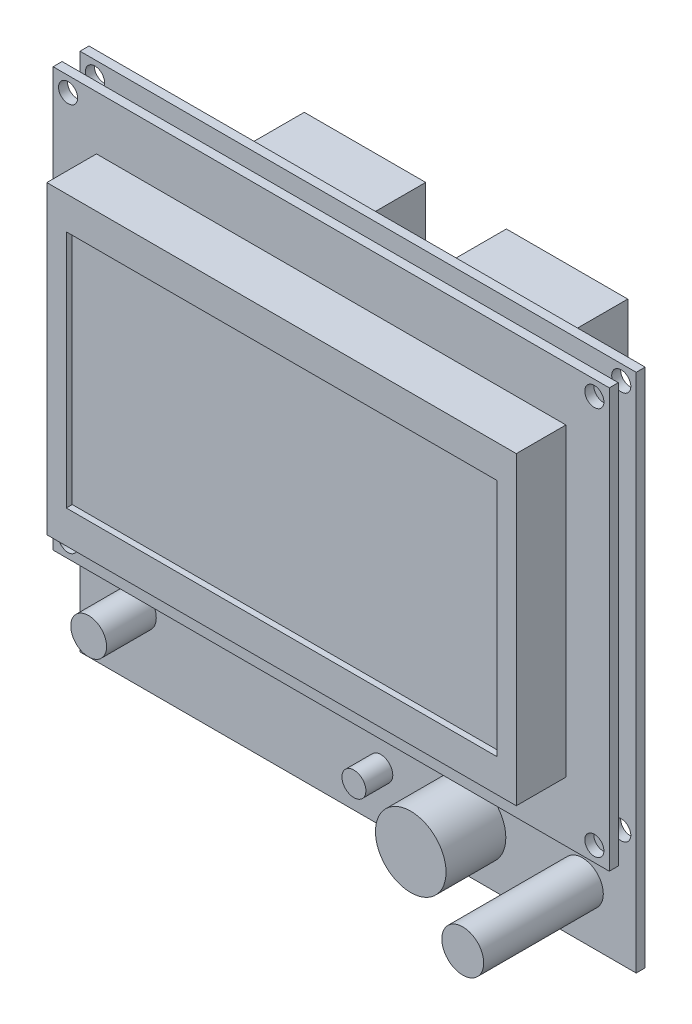
from build123d import *

# Parameters (mm, degrees)
ESBO_O1_W                  = 93
ESBO_O1_H                  = 87
RESSALTO_EXTRUS_O1_DEPTH   = 1.5
RESSALTO_EXTRUS_O2_START   = 3
ESBO_O3_W                  = 93
ESBO_O3_H                  = 70
RESSALTO_EXTRUS_O2_DEPTH   = 1.5
ESBO_O4_W                  = 78.5
ESBO_O4_H                  = 51
RESSALTO_EXTRUS_O3_DEPTH   = 8.3
ESBO_O5_W                  = 72
ESBO_O5_H                  = 40
CORTE_EXTRUS_O1_DEPTH      = 1
ESBO_O6_R                  = 3.5
RESSALTO_EXTRUS_O4_DEPTH   = 20
ESBO_O7_R                  = 2
RESSALTO_EXTRUS_O5_DEPTH   = 4.5
ESBO_O8_R                  = 5.9
RESSALTO_EXTRUS_O6_DEPTH   = 10
ESBO_O9_R                  = 3
RESSALTO_EXTRUS_O7_DEPTH   = 8.3
ESBO_O10_R                 = 1.6
CORTE_EXTRUS_O2_DEPTH      = 16.5
CORTE_EXTRUS_O2_DEPTH_BACK = 7
ESBO_O11_W                 = 20.3
ESBO_O11_H                 = 8.6
RESSALTO_EXTRUS_O8_DEPTH   = 15
ESBO_O12_W                 = 25.5
ESBO_O12_H                 = 26.5
RESSALTO_EXTRUS_O9_DEPTH   = 3


with BuildPart() as part:
    # Esboço1 → Ressalto-extrusão1 (new body)
    with BuildSketch(Plane.XY):
        Rectangle(ESBO_O1_W, ESBO_O1_H)
    extrude(amount=RESSALTO_EXTRUS_O1_DEPTH)

    # Esboço6 → Ressalto-extrusão4 (add)
    with BuildSketch(Plane.XY.offset(1.5)):
        with Locations((37.5, -34.8)):
            Circle(ESBO_O6_R)
    extrude(amount=RESSALTO_EXTRUS_O4_DEPTH)

    # Esboço7 → Ressalto-extrusão5 (add)
    with BuildSketch(Plane.XY.offset(1.5)):
        with Locations((3.8, -35.2)):
            Circle(ESBO_O7_R)
    extrude(amount=RESSALTO_EXTRUS_O5_DEPTH)

    # Esboço8 → Ressalto-extrusão6 (add)
    with BuildSketch(Plane.XY.offset(1.5)):
        with Locations((18.8, -34.8)):
            Circle(ESBO_O8_R)
    extrude(amount=RESSALTO_EXTRUS_O6_DEPTH)

    # Esboço9 → Ressalto-extrusão7 (add)
    with BuildSketch(Plane.XY.offset(1.5)):
        with Locations((-36.75, -32.2)):
            Circle(ESBO_O9_R)
    extrude(amount=RESSALTO_EXTRUS_O7_DEPTH)


with BuildPart() as body_2:
    # Esboço3 → Ressalto-extrusão2 (new body)
    with BuildSketch(Plane.XY.offset(1.5).offset(RESSALTO_EXTRUS_O2_START)):
        with Locations((0, 8.5)):
            Rectangle(ESBO_O3_W, ESBO_O3_H)
    extrude(amount=RESSALTO_EXTRUS_O2_DEPTH)

    # Esboço4 → Ressalto-extrusão3 (add)
    with BuildSketch(Plane.XY.offset(6)):
        with Locations((0, 9)):
            Rectangle(ESBO_O4_W, ESBO_O4_H)
    extrude(amount=RESSALTO_EXTRUS_O3_DEPTH)

    # Esboço5 → Corte-extrusão1 (cut)
    with BuildSketch(Plane.XY.offset(14.3)):
        with Locations((0, 9)):
            Rectangle(ESBO_O5_W, ESBO_O5_H)
    extrude(amount=-CORTE_EXTRUS_O1_DEPTH, mode=Mode.SUBTRACT)


with BuildPart() as corte_extrus_o2_tool:
    # Esboço10 → Corte-extrusão2 (new body, two sides)
    with BuildSketch(Plane.XY.offset(6)) as corte_extrus_o2_sk:
        with Locations((-44, 41)):
            Circle(ESBO_O10_R)
        with Locations((44, 41)):
            Circle(ESBO_O10_R)
        with Locations((44, -24)):
            Circle(ESBO_O10_R)
        with Locations((-44, -24)):
            Circle(ESBO_O10_R)
    extrude(amount=CORTE_EXTRUS_O2_DEPTH)
    extrude(corte_extrus_o2_sk.sketch, amount=-CORTE_EXTRUS_O2_DEPTH_BACK)


with BuildPart() as part_1:
    add(part.part)

    # Corte-extrusão2: cut by corte_extrus_o2_tool
    add(corte_extrus_o2_tool.part, mode=Mode.SUBTRACT)

    # Esboço11 → Ressalto-extrusão8 (add)
    with BuildSketch(Plane(origin=(0, 0, 0), x_dir=(-1, 0, 0), z_dir=(0, 0, -1))):
        with Locations((-18.438731824, 32.6)):
            Rectangle(ESBO_O11_W, ESBO_O11_H)
        with Locations((15.35, 32.6)):
            Rectangle(ESBO_O11_W, ESBO_O11_H)
    extrude(amount=RESSALTO_EXTRUS_O8_DEPTH)

    # Esboço12 → Ressalto-extrusão9 (add)
    with BuildSketch(Plane(origin=(0, 0, 0), x_dir=(-1, 0, 0), z_dir=(0, 0, -1))):
        with Locations((33.65, 8.25)):
            Rectangle(ESBO_O12_W, ESBO_O12_H)
    extrude(amount=RESSALTO_EXTRUS_O9_DEPTH)


with BuildPart() as body_2_1:
    add(body_2.part)

    # Corte-extrusão2: cut by corte_extrus_o2_tool
    add(corte_extrus_o2_tool.part, mode=Mode.SUBTRACT)


solid = Compound([part_1.part, body_2_1.part])
